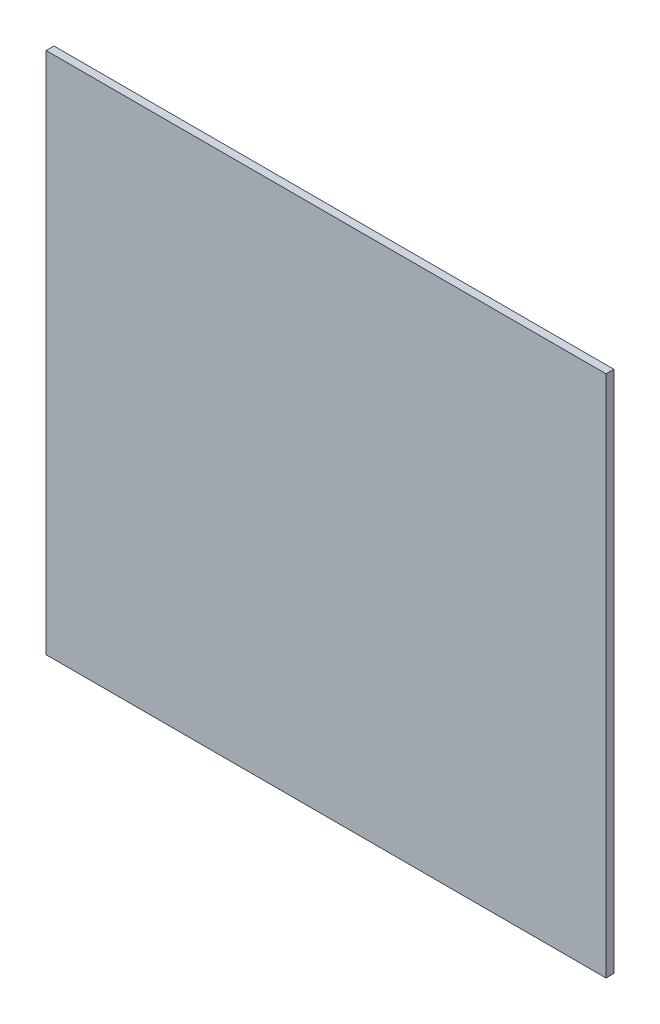
from build123d import *

# Parameters (mm, degrees)
SKETCH1_W           = 214
SKETCH1_H           = 200
BOSS_EXTRUDE1_DEPTH = 3


with BuildPart() as part:
    # Sketch1 → Boss-Extrude1 (new body)
    with BuildSketch(Plane.XY):
        Rectangle(SKETCH1_W, SKETCH1_H)
    extrude(amount=BOSS_EXTRUDE1_DEPTH)


solid = part.part
